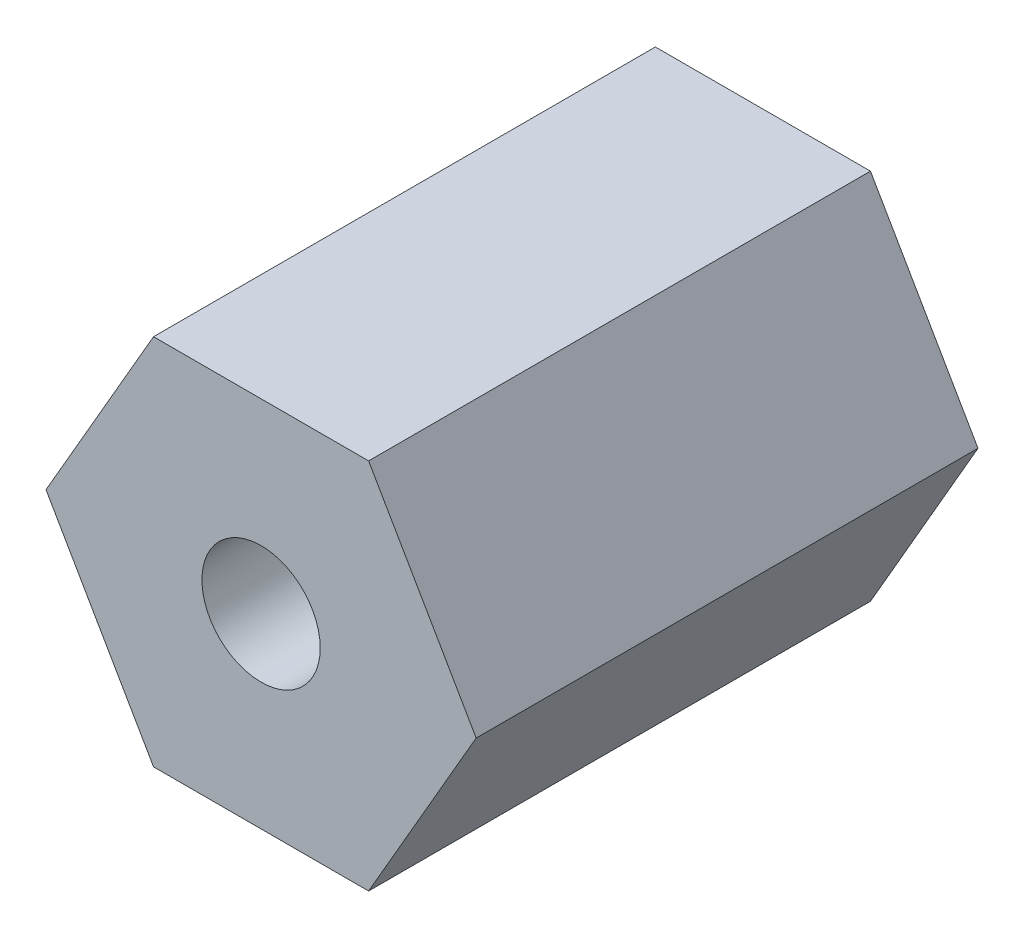
from build123d import *

# Parameters (mm, degrees)
EXTRUDE_1_DEPTH        = 14
HOLE_WIZARD_M4_2_D     = 3.3
HOLE_WIZARD_M4_2_DEPTH = 22.1
HOLE_WIZARD_M4_2_TIP   = 0.991420021


with BuildPart() as part:
    # 草图1 → 凸台-拉伸1 (new body)
    with BuildSketch(Plane.XY):
        Polygon((-3, 5.196152423), (-6, 0), (-3, -5.196152423), (3, -5.196152423), (6, 0), (3, 5.196152423), align=None)
    extrude(amount=EXTRUDE_1_DEPTH)

    # M4 螺纹孔2
    with Locations(Plane.XY.offset(14)):
        with Locations((0, 0)):
            Hole(HOLE_WIZARD_M4_2_D / 2, depth=HOLE_WIZARD_M4_2_DEPTH)
            with Locations((0, 0, -(HOLE_WIZARD_M4_2_DEPTH + HOLE_WIZARD_M4_2_TIP / 2))):  # 118° drill point
                Cone(0, HOLE_WIZARD_M4_2_D / 2, HOLE_WIZARD_M4_2_TIP, mode=Mode.SUBTRACT)


solid = part.part
